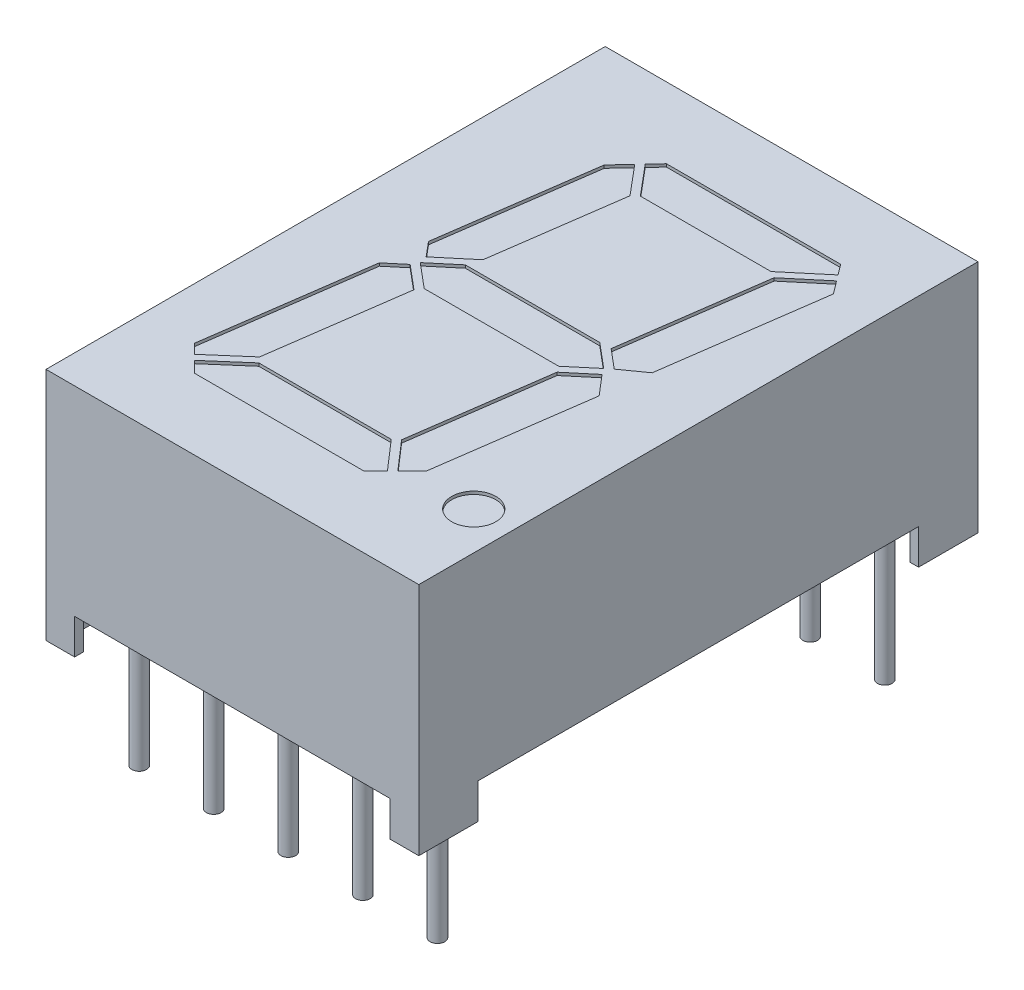
from build123d import *

# Parameters (mm, degrees)
SKETCH1_W          = 12.7
SKETCH1_H          = 19.05
EXTRUDE2_DEPTH     = 8
SKETCH2_W          = 5.375
SKETCH2_H          = 1.2
CUT_EXTRUDE2_DEPTH = 22.615388037
SKETCH3_W          = 15
SKETCH3_H          = 1.2
CUT_EXTRUDE3_DEPTH = 18.776828317
SKETCH6_R          = 0.75
CUT_EXTRUDE4_DEPTH = 0.1
SKETCH7_W          = 0.675
SKETCH7_H          = 1.725
CUT_EXTRUDE6_DEPTH = 1.2
SKETCH7_3_R        = 0.25
EXTRUDE3_DEPTH     = 1.2
SKETCH7_4_R        = 0.25
SKETCH7_4_W        = 0.675
SKETCH7_4_H        = 1.725
EXTRUDE4_DEPTH     = 4
SKETCH8_W          = 0.025316456
SKETCH8_H          = 0.026582278
CUT_EXTRUDE7_DEPTH = 0.01


with BuildPart() as part:
    # Sketch1 → Extrude2 (new body)
    with BuildSketch(Plane(origin=(0, 0, 0), x_dir=(1, 0, 0), z_dir=(0, 1, 0))):
        Rectangle(SKETCH1_W, SKETCH1_H)
    extrude(amount=-EXTRUDE2_DEPTH)

    # Sketch2 → Cut-Extrude2 (cut, through all)
    with BuildSketch(Plane.XY.offset(9.525)):
        with Locations((-2.6875, -7.4)):
            Rectangle(SKETCH2_W, SKETCH2_H)
        with Locations((2.6875, -7.4)):
            Rectangle(SKETCH2_W, SKETCH2_H)
    extrude(amount=-CUT_EXTRUDE2_DEPTH, mode=Mode.SUBTRACT)

    # Sketch3 → Cut-Extrude3 (cut, through all)
    with BuildSketch(Plane(origin=(6.35, 0, 0), x_dir=(0, 0, -1), z_dir=(1, 0, 0))):
        with Locations((0, -7.4)):
            Rectangle(SKETCH3_W, SKETCH3_H)
    extrude(amount=-CUT_EXTRUDE3_DEPTH, mode=Mode.SUBTRACT)

    # Sketch6 → Cut-Extrude4 (cut)
    with BuildSketch(Plane(origin=(0, 0, 0), x_dir=(-1, 0, 0), z_dir=(0, 1, 0))):
        Polygon((2.369327945, -6.551337949), (2.871364694, -6.012969448), (3.609010213, -0.764348857), (3.193357415, -0.268993141), (2.140736033, -1.152247354), (1.523595157, -5.543432859), align=None)
        Polygon((-4.085129092, -7.11), (1.848367154, -7.11), (2.197547933, -6.735549459), (1.337009761, -5.71), (-3.11477849, -5.71), (-4.355553886, -6.751134178), align=None)
        Polygon((3.244309033, 0.226239657), (3.815599337, 0.705609141), (4.591456053, 6.226116524), (4.264982567, 6.552590009), (3.078645126, 5.521322605), (2.430446711, 0.909151231), align=None)
        Polygon((-4.837397871, -6.111705612), (-4.506214117, -6.551201299), (-3.348930492, -5.580125036), (-2.664827887, -0.712482073), (-3.321818844, -0.161201203), (-4.076647, -0.698681899), align=None)
        Polygon((-2.290772485, -0.7), (2.290772485, -0.7), (3.125, 0), (2.290772485, 0.7), (-2.290772485, 0.7), (-3.125, 0), align=None)
        Polygon((2.914630368, 5.71), (4.087774201, 6.729798375), (3.707572576, 7.11), (-2.067614222, 7.11), (-2.466679527, 6.710934695), (-1.596580271, 5.71), align=None)
        Polygon((-3.128274394, 6.049339828), (-3.854004606, 0.88550105), (-3.271336503, 0.203560916), (-2.437787921, 0.902991224), (-1.785257666, 5.545985243), (-2.643887893, 6.533726329), align=None)
        with Locations(Location((-5.058047449, 6.36, 0), (0, 0, 90))):
            Circle(SKETCH6_R)
    extrude(amount=-CUT_EXTRUDE4_DEPTH, mode=Mode.SUBTRACT)

    # Sketch7 → Cut-Extrude6 (cut)
    with BuildSketch(Plane.XZ.offset(8)):
        with Locations((-5.7125, 8.3625)):
            Rectangle(SKETCH7_W, SKETCH7_H)
        with Locations((-5.7125, -8.3625)):
            Rectangle(SKETCH7_W, SKETCH7_H)
        with Locations((5.7125, -8.3625)):
            Rectangle(SKETCH7_W, SKETCH7_H)
        with Locations((5.7125, 8.3625)):
            Rectangle(SKETCH7_W, SKETCH7_H)
    extrude(amount=-CUT_EXTRUDE6_DEPTH, mode=Mode.SUBTRACT)

    # Sketch7_3 → Extrude3 (add)
    with BuildSketch(Plane.XZ.offset(8)):
        with Locations(Location((-5.08, 7.62, 0), (0, 0, 270))):
            Circle(SKETCH7_3_R)
        with Locations(Location((-2.54, 7.62, 0), (0, 0, 270))):
            Circle(SKETCH7_3_R)
        with Locations(Location((0, 7.62, 0), (0, 0, 270))):
            Circle(SKETCH7_3_R)
        with Locations(Location((5.08, 7.62, 0), (0, 0, 270))):
            Circle(SKETCH7_3_R)
        with Locations(Location((2.54, 7.62, 0), (0, 0, 270))):
            Circle(SKETCH7_3_R)
        with Locations(Location((2.54, -7.62, 0), (0, 0, 270))):
            Circle(SKETCH7_3_R)
        with Locations(Location((5.08, -7.62, 0), (0, 0, 270))):
            Circle(SKETCH7_3_R)
        with Locations(Location((0, -7.62, 0), (0, 0, 270))):
            Circle(SKETCH7_3_R)
        with Locations(Location((-2.54, -7.62, 0), (0, 0, 270))):
            Circle(SKETCH7_3_R)
        with Locations(Location((-5.08, -7.62, 0), (0, 0, 270))):
            Circle(SKETCH7_3_R)
    extrude(amount=-EXTRUDE3_DEPTH)


with BuildPart() as extrude4_tool:
    # Sketch7_4 → Extrude4 (new body)
    with BuildSketch(Plane.XZ.offset(8)):
        with Locations(Location((-5.08, 7.62, 0), (0, 0, 270))):
            Circle(SKETCH7_4_R)
        with Locations(Location((-2.54, 7.62, 0), (0, 0, 270))):
            Circle(SKETCH7_4_R)
        with Locations(Location((0, 7.62, 0), (0, 0, 270))):
            Circle(SKETCH7_4_R)
        with Locations(Location((5.08, 7.62, 0), (0, 0, 270))):
            Circle(SKETCH7_4_R)
        with Locations(Location((2.54, 7.62, 0), (0, 0, 270))):
            Circle(SKETCH7_4_R)
        with Locations(Location((2.54, -7.62, 0), (0, 0, 270))):
            Circle(SKETCH7_4_R)
        with Locations(Location((5.08, -7.62, 0), (0, 0, 270))):
            Circle(SKETCH7_4_R)
        with Locations(Location((0, -7.62, 0), (0, 0, 270))):
            Circle(SKETCH7_4_R)
        with Locations(Location((-2.54, -7.62, 0), (0, 0, 270))):
            Circle(SKETCH7_4_R)
        with Locations(Location((-5.08, -7.62, 0), (0, 0, 270))):
            Circle(SKETCH7_4_R)
        with Locations((-5.7125, 8.3625)):
            Rectangle(SKETCH7_4_W, SKETCH7_4_H)
        with Locations((-5.7125, -8.3625)):
            Rectangle(SKETCH7_4_W, SKETCH7_4_H)
        with Locations((5.7125, -8.3625)):
            Rectangle(SKETCH7_4_W, SKETCH7_4_H)
        with Locations((5.7125, 8.3625)):
            Rectangle(SKETCH7_4_W, SKETCH7_4_H)
    extrude(amount=EXTRUDE4_DEPTH)


with BuildPart() as part_1:
    add(part.part)


with BuildPart() as part_2:
    # Extrude4: joined with extrude4_tool
    add(part_1.part.fuse(extrude4_tool.part, tol=0.00001))


with BuildPart() as extrude4_kept_piece:
    # of the separate pieces the step leaves, the one the design keeps (extrude4_pieces_kept)
    add(part_2.part.solids().sort_by_distance((-6.35, 0, -9.525))[0])

    # Sketch8 → Cut-Extrude7 (cut)
    with BuildSketch(Plane.XZ.offset(6.8)):
        Polygon((0.572151899, 6.217942251), (0.595609177, 6.292625795), (0.620352057, 6.292625795), (0.636768196, 6.242289561), (0.652294304, 6.292625795), (0.678026108, 6.292625795), (0.701265823, 6.217942251), (0.676087816, 6.217942251), (0.663093354, 6.269425637), (0.646677215, 6.217942251), (0.625178006, 6.217942251), (0.608860759, 6.269425637), (0.596044304, 6.217942251), align=None)
        Polygon((0.437974684, 6.217942251), (0.461431962, 6.292625795), (0.486174842, 6.292625795), (0.502590981, 6.242289561), (0.518117089, 6.292625795), (0.543848892, 6.292625795), (0.567088608, 6.217942251), (0.541910601, 6.217942251), (0.528916139, 6.269425637), (0.5125, 6.217942251), (0.491000791, 6.217942251), (0.474683544, 6.269425637), (0.461867089, 6.217942251), align=None)
        Polygon((0.303797468, 6.217942251), (0.327254747, 6.292625795), (0.351997627, 6.292625795), (0.368413766, 6.242289561), (0.383939873, 6.292625795), (0.409671677, 6.292625795), (0.432911392, 6.217942251), (0.407733386, 6.217942251), (0.394738924, 6.269425637), (0.378322785, 6.217942251), (0.356823576, 6.217942251), (0.340506329, 6.269425637), (0.327689873, 6.217942251), align=None)
        with Locations((0.275949367, 6.279334656)):
            Rectangle(SKETCH8_W, SKETCH8_H)
        with BuildLine():
            add(Edge.make_bspline(
                [(0.159493671, 6.261454909), (0.159530199, 6.262677023), (0.159601928, 6.265076848), (0.16021109, 6.268584813), (0.161206614, 6.271908097), (0.162570953, 6.275070812), (0.164384941, 6.278026178), (0.166539954, 6.280844745), (0.169151869, 6.283428707), (0.172088905, 6.285867468), (0.175386832, 6.288049863), (0.178989454, 6.289950002), (0.182859774, 6.29157472), (0.187013794, 6.29290641), (0.191459372, 6.293897177), (0.196177149, 6.294620494), (0.201170497, 6.295094002), (0.204594085, 6.295135943), (0.206348892, 6.295157441)],
                knots=[0, 0, 0, 0, 0.907421153, 1.781872267, 2.635683434, 3.480115191, 4.332689235, 5.205575272, 6.109500117, 7.055808355, 8.037942167, 9.041423561, 10.07750834, 11.152467461, 12.277657752, 13.45734338, 14.696726425, 16, 16, 16, 16], degree=3))
            add(Edge.make_bspline(
                [(0.206348892, 6.295157441), (0.208366877, 6.295130176), (0.212275063, 6.295077372), (0.217942631, 6.294691999), (0.223206098, 6.29400405), (0.228103845, 6.293047469), (0.232708145, 6.291844184), (0.23714149, 6.29055354), (0.241422782, 6.28908896), (0.244195874, 6.287988823), (0.24556962, 6.287443833)],
                knots=[0, 0, 0, 0, 1.203182053, 2.33017619, 3.384818652, 4.366208123, 5.30340534, 6.221361684, 7.118890722, 8, 8, 8, 8], degree=3))
            Line((0.24556962, 6.287443833), (0.24556962, 6.263511871))
            Line((0.24556962, 6.263511871), (0.242721519, 6.263511871))
            add(Edge.make_bspline(
                [(0.242721519, 6.263511871), (0.241355956, 6.264592834), (0.238632846, 6.266748413), (0.234205888, 6.269516767), (0.229546876, 6.271889778), (0.224708482, 6.2738724), (0.219807114, 6.275448014), (0.214938046, 6.27657492), (0.210169064, 6.277314284), (0.207010742, 6.277395846), (0.205458861, 6.277435922)],
                knots=[0, 0, 0, 0, 1.030738938, 2.055426519, 3.085610749, 4.123842265, 5.148648843, 6.130724483, 7.081507926, 8, 8, 8, 8], degree=3))
            add(Edge.make_bspline(
                [(0.205458861, 6.277435922), (0.205030115, 6.277434621), (0.204112202, 6.277431837), (0.202643054, 6.277310522), (0.200986711, 6.277182677), (0.199205972, 6.276986563), (0.197418768, 6.276755418), (0.19575852, 6.276408951), (0.194257758, 6.2760398), (0.193351089, 6.275672534), (0.192919304, 6.275497631)],
                knots=[0, 0, 0, 0, 0.806537132, 1.726733348, 2.77251655, 3.932999672, 5.098049949, 6.161349231, 7.124375527, 8, 8, 8, 8], degree=3))
            add(Edge.make_bspline(
                [(0.192919304, 6.275497631), (0.192439817, 6.275269395), (0.191497525, 6.274820864), (0.190194994, 6.274006953), (0.189024509, 6.273112209), (0.187963807, 6.272150475), (0.187101412, 6.270987487), (0.186480251, 6.269588216), (0.18613568, 6.267938924), (0.186096608, 6.266763762), (0.186075949, 6.266142409)],
                knots=[0, 0, 0, 0, 1.02474257, 2.013837243, 2.958431669, 3.867978675, 4.769292696, 5.732237074, 6.800947934, 8, 8, 8, 8], degree=3))
            add(Edge.make_bspline(
                [(0.186075949, 6.266142409), (0.186107411, 6.265596543), (0.186169273, 6.264523209), (0.186750779, 6.26299478), (0.187634826, 6.261574644), (0.188914241, 6.260309307), (0.190527919, 6.259183195), (0.192458907, 6.258172432), (0.194732757, 6.257336674), (0.19636997, 6.256898802), (0.197231013, 6.256668517)],
                knots=[0, 0, 0, 0, 0.825427492, 1.623033598, 2.45033906, 3.348940377, 4.33183287, 5.428402891, 6.647546779, 8, 8, 8, 8], degree=3))
            add(Edge.make_bspline(
                [(0.197231013, 6.256668517), (0.199200253, 6.256223312), (0.203235465, 6.255311034), (0.209375278, 6.25412358), (0.215513981, 6.252897709), (0.219470238, 6.251683394), (0.221400316, 6.251090985)],
                knots=[0, 0, 0, 0, 0.976118991, 2.000185432, 3.024380873, 4, 4, 4, 4], degree=3))
            add(Edge.make_bspline(
                [(0.221400316, 6.251090985), (0.222438469, 6.250737262), (0.224459331, 6.250048708), (0.227358523, 6.248896059), (0.230001771, 6.247590925), (0.23245931, 6.246268887), (0.234651974, 6.24478883), (0.236646608, 6.24325607), (0.238399268, 6.241603266), (0.239925706, 6.239853773), (0.241268572, 6.238017411), (0.242421982, 6.23607027), (0.243383004, 6.234003821), (0.244206396, 6.231848423), (0.244817623, 6.229573888), (0.245240059, 6.227197471), (0.245538122, 6.224713985), (0.245558978, 6.223019649), (0.24556962, 6.222155067)],
                knots=[0, 0, 0, 0, 1.287376879, 2.505999703, 3.65855109, 4.746193839, 5.778582289, 6.760029101, 7.696159662, 8.601061861, 9.48181646, 10.363080883, 11.252765705, 12.153987336, 13.068239035, 14.012364187, 14.985753787, 16, 16, 16, 16], degree=3))
            add(Edge.make_bspline(
                [(0.24556962, 6.222155067), (0.24553232, 6.220998921), (0.245458913, 6.218723646), (0.244857463, 6.215394624), (0.243830953, 6.212245805), (0.242444593, 6.209242649), (0.2406171, 6.206428386), (0.238424977, 6.203750899), (0.235814667, 6.201258403), (0.23282934, 6.198959767), (0.229542493, 6.196880961), (0.226008488, 6.195044253), (0.222229636, 6.193537806), (0.218249751, 6.192256575), (0.214030359, 6.19130418), (0.209593388, 6.190584602), (0.204919526, 6.190171601), (0.201728115, 6.190120326), (0.200098892, 6.19009415)],
                knots=[0, 0, 0, 0, 0.894901293, 1.761149761, 2.608783409, 3.453876344, 4.314933854, 5.200038827, 6.12799933, 7.103249695, 8.113098521, 9.136064399, 10.182719798, 11.259667356, 12.370545059, 13.528828137, 14.738461593, 16, 16, 16, 16], degree=3))
            add(Edge.make_bspline(
                [(0.200098892, 6.19009415), (0.198430241, 6.190116542), (0.195095767, 6.19016129), (0.190113794, 6.19053626), (0.185156379, 6.191102761), (0.180284815, 6.191902215), (0.175602308, 6.192919871), (0.171185694, 6.194005829), (0.167106724, 6.195246219), (0.164532999, 6.196200264), (0.163291139, 6.196660605)],
                knots=[0, 0, 0, 0, 1.065379838, 2.128953261, 3.188461447, 4.250817766, 5.279613205, 6.247547721, 7.154416075, 8, 8, 8, 8], degree=3))
            Line((0.163291139, 6.196660605), (0.163291139, 6.219208074))
            Line((0.163291139, 6.219208074), (0.166119462, 6.219208074))
            add(Edge.make_bspline(
                [(0.166119462, 6.219208074), (0.167192422, 6.21840787), (0.169386652, 6.216771432), (0.173045405, 6.214685455), (0.177009465, 6.212735941), (0.181274367, 6.211014148), (0.185746907, 6.209593547), (0.190324453, 6.208564503), (0.194951518, 6.20792538), (0.198053109, 6.207852247), (0.19960443, 6.207815669)],
                knots=[0, 0, 0, 0, 0.89224925, 1.824673196, 2.804309561, 3.838364047, 4.890042674, 5.931526337, 6.965412421, 8, 8, 8, 8], degree=3))
            add(Edge.make_bspline(
                [(0.19960443, 6.207815669), (0.20069973, 6.207839878), (0.202889476, 6.207888279), (0.206163883, 6.208237533), (0.209398675, 6.208909274), (0.211441573, 6.209723611), (0.212460443, 6.210129751)],
                knots=[0, 0, 0, 0, 0.998993879, 1.997209027, 3.00113285, 4, 4, 4, 4], degree=3))
            add(Edge.make_bspline(
                [(0.212460443, 6.210129751), (0.212893922, 6.210331234), (0.213760592, 6.210734065), (0.214967595, 6.211506391), (0.216070899, 6.212436108), (0.217071904, 6.213488502), (0.21791996, 6.214657837), (0.21855762, 6.215927596), (0.218918439, 6.217289575), (0.218964276, 6.218223744), (0.218987342, 6.218693833)],
                knots=[0, 0, 0, 0, 1.005454979, 2.010239304, 3.005296729, 4.036100111, 5.060531193, 6.034954812, 7.011155677, 8, 8, 8, 8], degree=3))
            add(Edge.make_bspline(
                [(0.218987342, 6.218693833), (0.218952547, 6.219331764), (0.218886059, 6.220550792), (0.218286061, 6.222264488), (0.217288392, 6.2237276), (0.216135293, 6.224720594), (0.215018314, 6.225419353), (0.213977797, 6.225924593), (0.212778346, 6.226438016), (0.211400897, 6.226927213), (0.209865762, 6.227421259), (0.20815684, 6.227895929), (0.206274232, 6.228345489), (0.204958342, 6.228631641), (0.204272152, 6.228780858)],
                knots=[0, 0, 0, 0, 1.174343879, 2.244064321, 3.303704314, 4.407076671, 5.02483983, 5.732197225, 6.53898402, 7.431906431, 8.428480183, 9.514816237, 10.704066255, 12, 12, 12, 12], degree=3))
            add(Edge.make_bspline(
                [(0.204272152, 6.228780858), (0.202439527, 6.229157579), (0.198838824, 6.22989775), (0.193433749, 6.230992047), (0.187940695, 6.232304565), (0.184270145, 6.233433777), (0.182357595, 6.234022156)],
                knots=[0, 0, 0, 0, 0.995788186, 1.956503735, 2.935230479, 4, 4, 4, 4], degree=3))
            add(Edge.make_bspline(
                [(0.182357595, 6.234022156), (0.181411038, 6.234341397), (0.179559421, 6.234965885), (0.176918823, 6.236052203), (0.17447165, 6.237226061), (0.172205016, 6.23846803), (0.17012965, 6.239810463), (0.16824336, 6.241235796), (0.166545403, 6.242740579), (0.165056655, 6.244356299), (0.163727897, 6.246066647), (0.162615553, 6.24791726), (0.161619968, 6.249860789), (0.160866813, 6.251954233), (0.160242304, 6.25415276), (0.159820561, 6.256484694), (0.159526198, 6.258928912), (0.159504634, 6.260603512), (0.159493671, 6.261454909)],
                knots=[0, 0, 0, 0, 1.237326419, 2.420410185, 3.534642089, 4.598489486, 5.620241961, 6.59385002, 7.525152549, 8.426792174, 9.312230456, 10.203151844, 11.098070343, 12.012931196, 12.954244379, 13.926618287, 14.945853925, 16, 16, 16, 16], degree=3))
        make_face()
        with BuildLine():
            Line((0.067088608, 6.292625795), (0.091139241, 6.292625795))
            Line((0.091139241, 6.292625795), (0.091139241, 6.284793517))
            add(Edge.make_bspline(
                [(0.091139241, 6.284793517), (0.092232434, 6.285602312), (0.094340096, 6.287161656), (0.097514655, 6.289238718), (0.100532955, 6.29102314), (0.103463307, 6.292546258), (0.106469584, 6.293758428), (0.109707718, 6.294576809), (0.113209314, 6.295079533), (0.115636384, 6.295130894), (0.116890823, 6.295157441)],
                knots=[0, 0, 0, 0, 1.150945962, 2.219006967, 3.209666795, 4.118194914, 5.012574058, 5.946577101, 6.93868214, 8, 8, 8, 8], degree=3))
            add(Edge.make_bspline(
                [(0.116890823, 6.295157441), (0.117907098, 6.295134493), (0.119886079, 6.295089807), (0.122764378, 6.294748086), (0.125466344, 6.294199677), (0.127995181, 6.293431271), (0.130344881, 6.29242824), (0.132488561, 6.291156605), (0.134491138, 6.289723891), (0.136273085, 6.288017526), (0.137888631, 6.286119607), (0.139271202, 6.283987198), (0.140448907, 6.281654258), (0.141390007, 6.279102409), (0.142145096, 6.276344104), (0.142669028, 6.273364857), (0.142989621, 6.270177729), (0.14302156, 6.267982599), (0.143037975, 6.266854434)],
                knots=[0, 0, 0, 0, 1.108959949, 2.159465255, 3.158589008, 4.114545495, 5.039534357, 5.93921201, 6.830099133, 7.720870013, 8.624681761, 9.544731627, 10.487599671, 11.471264588, 12.508152322, 13.604835107, 14.769030043, 16, 16, 16, 16], degree=3))
            Line((0.143037975, 6.266854434), (0.143037975, 6.217942251))
            Line((0.143037975, 6.217942251), (0.118987342, 6.217942251))
            Line((0.118987342, 6.217942251), (0.118987342, 6.255521365))
            add(Edge.make_bspline(
                [(0.118987342, 6.255521365), (0.118985706, 6.256437836), (0.118982576, 6.258192051), (0.118900237, 6.260697858), (0.118779336, 6.262966031), (0.118640631, 6.265008059), (0.118387615, 6.26685481), (0.118009906, 6.268520971), (0.11753908, 6.270040573), (0.117074761, 6.270947274), (0.116851266, 6.271383707)],
                knots=[0, 0, 0, 0, 1.361401701, 2.605856924, 3.723918663, 4.735739235, 5.645738665, 6.489217889, 7.27279937, 8, 8, 8, 8], degree=3))
            add(Edge.make_bspline(
                [(0.116851266, 6.271383707), (0.116621257, 6.271782412), (0.11616908, 6.272566233), (0.115248816, 6.273572545), (0.114169974, 6.274416295), (0.11289277, 6.275074396), (0.111403203, 6.275564899), (0.109682344, 6.27594547), (0.107690603, 6.276117348), (0.106283135, 6.276151839), (0.105537975, 6.276170099)],
                knots=[0, 0, 0, 0, 0.849004071, 1.669068917, 2.503060811, 3.370079215, 4.310762265, 5.396376419, 6.621555549, 8, 8, 8, 8], degree=3))
            add(Edge.make_bspline(
                [(0.105537975, 6.276170099), (0.104997032, 6.27615026), (0.103885616, 6.276109498), (0.102168163, 6.275917958), (0.100378903, 6.275518799), (0.097860234, 6.274873854), (0.094695025, 6.27368), (0.09233549, 6.272326853), (0.091139241, 6.271640827)],
                knots=[0, 0, 0, 0, 0.638062719, 1.310959128, 2.033463623, 2.796942592, 4.376095945, 6, 6, 6, 6], degree=3))
            Line((0.091139241, 6.271640827), (0.091139241, 6.217942251))
            Line((0.091139241, 6.217942251), (0.067088608, 6.217942251))
            Line((0.067088608, 6.217942251), (0.067088608, 6.292625795))
        make_face()
        with BuildLine():
            Line((-0.030379747, 6.292625795), (-0.006329114, 6.292625795))
            Line((-0.006329114, 6.292625795), (-0.006329114, 6.255046681))
            add(Edge.make_bspline(
                [(-0.006329114, 6.255046681), (-0.006304108, 6.253516692), (-0.006254136, 6.2504592), (-0.005977585, 6.246696106), (-0.005593098, 6.243854567), (-0.005225559, 6.242022978), (-0.004793687, 6.240474861), (-0.004381426, 6.2395891), (-0.004193038, 6.23918434)],
                knots=[0, 0, 0, 0, 1.709111167, 3.415443484, 4.21113913, 4.910175115, 5.501990373, 6, 6, 6, 6], degree=3))
            add(Edge.make_bspline(
                [(-0.004193038, 6.23918434), (-0.003948577, 6.238786277), (-0.003469277, 6.238005818), (-0.002531926, 6.236992942), (-0.001438143, 6.236163573), (-0.000166967, 6.235484106), (0.001321142, 6.235004918), (0.003045059, 6.234652164), (0.005025244, 6.23444161), (0.006434073, 6.234413057), (0.007179589, 6.234397947)],
                knots=[0, 0, 0, 0, 0.860202684, 1.686548532, 2.528236983, 3.382486038, 4.33249885, 5.401154041, 6.624757403, 8, 8, 8, 8], degree=3))
            add(Edge.make_bspline(
                [(0.007179589, 6.234397947), (0.008310478, 6.234458048), (0.010618173, 6.234580689), (0.013493483, 6.235247355), (0.015810821, 6.23610732), (0.017668538, 6.236857755), (0.01957626, 6.237831856), (0.020855802, 6.238553297), (0.021518987, 6.238927219)],
                knots=[0, 0, 0, 0, 1.33818541, 2.730705359, 3.468371228, 4.262126284, 5.099261778, 6, 6, 6, 6], degree=3))
            Line((0.021518987, 6.238927219), (0.021518987, 6.292625795))
            Line((0.021518987, 6.292625795), (0.04556962, 6.292625795))
            Line((0.04556962, 6.292625795), (0.04556962, 6.217942251))
            Line((0.04556962, 6.217942251), (0.021518987, 6.217942251))
            Line((0.021518987, 6.217942251), (0.021518987, 6.225774529))
            add(Edge.make_bspline(
                [(0.021518987, 6.225774529), (0.020461581, 6.224968378), (0.018403276, 6.223399156), (0.015224038, 6.221358735), (0.01214014, 6.219559966), (0.009087131, 6.218047149), (0.005972176, 6.216840374), (0.002709417, 6.216029385), (-0.000706989, 6.215485583), (-0.003043704, 6.215435889), (-0.004232595, 6.215410605)],
                knots=[0, 0, 0, 0, 1.126119141, 2.192057864, 3.198061997, 4.149848529, 5.076251285, 6.021887753, 6.99356175, 8, 8, 8, 8], degree=3))
            add(Edge.make_bspline(
                [(-0.004232595, 6.215410605), (-0.00522886, 6.215436006), (-0.007173746, 6.215485592), (-0.010008596, 6.215795144), (-0.012679702, 6.216346367), (-0.015173087, 6.217142223), (-0.017508773, 6.218133582), (-0.019682445, 6.219337562), (-0.021668294, 6.220800843), (-0.023496446, 6.222460782), (-0.025135546, 6.224352079), (-0.026532456, 6.226481457), (-0.027736818, 6.228818377), (-0.028686083, 6.231381015), (-0.029477407, 6.234147286), (-0.02998217, 6.237145916), (-0.030339823, 6.240355802), (-0.030366173, 6.242571952), (-0.030379747, 6.243713612)],
                knots=[0, 0, 0, 0, 1.08828964, 2.12453497, 3.110382522, 4.062402335, 4.978696626, 5.878225494, 6.769849763, 7.667011675, 8.57076823, 9.495541561, 10.442454184, 11.436213583, 12.475881554, 13.580560132, 14.753614518, 16, 16, 16, 16], degree=3))
            Line((-0.030379747, 6.243713612), (-0.030379747, 6.292625795))
        make_face()
        Polygon((-0.125316456, 6.292625795), (-0.053164557, 6.292625795), (-0.053164557, 6.192625795), (-0.078481013, 6.192625795), (-0.078481013, 6.273638453), (-0.125316456, 6.273638453), align=None)
        Polygon((-0.212658228, 6.292625795), (-0.140506329, 6.292625795), (-0.140506329, 6.192625795), (-0.212658228, 6.192625795), (-0.212658228, 6.211613137), (-0.165822785, 6.211613137), (-0.165822785, 6.229334656), (-0.208860759, 6.229334656), (-0.208860759, 6.248321998), (-0.165822785, 6.248321998), (-0.165822785, 6.273638453), (-0.212658228, 6.273638453), align=None)
        with BuildLine():
            add(Edge.make_bspline(
                [(-0.329113924, 6.242724688), (-0.329094609, 6.243872376), (-0.329056357, 6.246145263), (-0.328761165, 6.249510069), (-0.32823514, 6.252775745), (-0.327555959, 6.255959993), (-0.326633453, 6.259038921), (-0.325551739, 6.262046498), (-0.324242093, 6.264951992), (-0.322737241, 6.267753426), (-0.321087768, 6.270425529), (-0.319313019, 6.272945738), (-0.31746724, 6.275328955), (-0.315477927, 6.277523849), (-0.313398746, 6.279565869), (-0.311223217, 6.281456683), (-0.308918153, 6.283160114), (-0.30731099, 6.284182998), (-0.30650712, 6.284694624)],
                knots=[0, 0, 0, 0, 1.105570398, 2.18947457, 3.250358341, 4.290584537, 5.323553275, 6.344225964, 7.367641686, 8.3905646, 9.405808457, 10.390761353, 11.358902336, 12.307789878, 13.241960776, 14.165076779, 15.082208636, 16, 16, 16, 16], degree=3))
            add(Edge.make_bspline(
                [(-0.30650712, 6.284694624), (-0.305267933, 6.285406945), (-0.302783236, 6.286835222), (-0.298798778, 6.288501062), (-0.294677169, 6.289915284), (-0.290317988, 6.290928725), (-0.285679267, 6.29169856), (-0.280674456, 6.292246731), (-0.27526755, 6.292552234), (-0.271532557, 6.292600716), (-0.269600475, 6.292625795)],
                knots=[0, 0, 0, 0, 0.896321744, 1.797216976, 2.705381885, 3.628777036, 4.602292017, 5.655629376, 6.787275635, 8, 8, 8, 8], degree=3))
            Line((-0.269600475, 6.292625795), (-0.234177215, 6.292625795))
            Line((-0.234177215, 6.292625795), (-0.234177215, 6.192625795))
            Line((-0.234177215, 6.192625795), (-0.270609177, 6.192625795))
            add(Edge.make_bspline(
                [(-0.270609177, 6.192625795), (-0.272587873, 6.192642605), (-0.276404533, 6.19267503), (-0.281921849, 6.193089957), (-0.287024188, 6.19369572), (-0.291713768, 6.194589906), (-0.296016217, 6.195704487), (-0.299933509, 6.197093018), (-0.303549742, 6.198585635), (-0.305728277, 6.199860189), (-0.306784019, 6.200477852)],
                knots=[0, 0, 0, 0, 1.267083275, 2.444046388, 3.541868212, 4.55639609, 5.499737919, 6.385160515, 7.217431253, 8, 8, 8, 8], degree=3))
            add(Edge.make_bspline(
                [(-0.306784019, 6.200477852), (-0.307634972, 6.201014393), (-0.309327097, 6.202081306), (-0.311728312, 6.203863159), (-0.313957739, 6.205819236), (-0.316086242, 6.207871054), (-0.318066059, 6.210073941), (-0.319909259, 6.212412648), (-0.321613076, 6.214890742), (-0.323171039, 6.217500211), (-0.324591854, 6.220230263), (-0.32578116, 6.223103322), (-0.326830509, 6.226081852), (-0.327636046, 6.229190815), (-0.32833396, 6.232398651), (-0.328768694, 6.235739995), (-0.329055305, 6.239192483), (-0.32909422, 6.241537373), (-0.329113924, 6.242724688)],
                knots=[0, 0, 0, 0, 0.964065863, 1.917049184, 2.86229036, 3.805247319, 4.749389377, 5.698846072, 6.657678277, 7.629829384, 8.610569287, 9.604676042, 10.607940105, 11.6349849, 12.681042988, 13.752616828, 14.862056989, 16, 16, 16, 16], degree=3))
        make_face()
        with BuildLine():
            add(Edge.make_bspline(
                [(-0.302531646, 6.24256646), (-0.302488343, 6.24098803), (-0.30240473, 6.23794023), (-0.301699336, 6.233544586), (-0.300560086, 6.229501636), (-0.299222393, 6.22638922), (-0.297885002, 6.224115902), (-0.296757478, 6.222517632), (-0.295507812, 6.221003432), (-0.294117203, 6.219594592), (-0.292582019, 6.218287556), (-0.29092076, 6.217058646), (-0.289120719, 6.21593), (-0.287847688, 6.215269994), (-0.287203323, 6.214935922)],
                knots=[0, 0, 0, 0, 1.694683197, 3.272273219, 4.767406206, 6.197615014, 6.895990032, 7.597410435, 8.296503208, 9.002591366, 9.720792421, 10.460154445, 11.220583224, 12, 12, 12, 12], degree=3))
            add(Edge.make_bspline(
                [(-0.287203323, 6.214935922), (-0.286528388, 6.214629407), (-0.285190619, 6.214021875), (-0.283120344, 6.213287788), (-0.281027643, 6.212725461), (-0.278833415, 6.212253038), (-0.276356655, 6.211975902), (-0.273434164, 6.211763226), (-0.269977491, 6.211626298), (-0.267490895, 6.211617728), (-0.266159019, 6.211613137)],
                knots=[0, 0, 0, 0, 0.826913061, 1.638999358, 2.447478739, 3.243919028, 4.140906711, 5.225381046, 6.513851968, 8, 8, 8, 8], degree=3))
            Line((-0.266159019, 6.211613137), (-0.259493671, 6.211613137))
            Line((-0.259493671, 6.211613137), (-0.259493671, 6.273638453))
            Line((-0.259493671, 6.273638453), (-0.266159019, 6.273638453))
            add(Edge.make_bspline(
                [(-0.266159019, 6.273638453), (-0.26691721, 6.273633408), (-0.268380945, 6.273623667), (-0.270497399, 6.273584564), (-0.272462161, 6.273524247), (-0.274269511, 6.273452405), (-0.275925648, 6.273337502), (-0.277413482, 6.273168905), (-0.278755832, 6.273024518), (-0.280323467, 6.272757398), (-0.282176615, 6.272340943), (-0.284337881, 6.271662851), (-0.286478414, 6.270812432), (-0.287866987, 6.270127468), (-0.288568038, 6.26978165)],
                knots=[0, 0, 0, 0, 1.186775798, 2.291144404, 3.313233901, 4.263515562, 5.122260739, 5.910868134, 6.60717912, 7.234883681, 8.398964994, 9.577230746, 10.776813768, 12, 12, 12, 12], degree=3))
            add(Edge.make_bspline(
                [(-0.288568038, 6.26978165), (-0.289151752, 6.269438173), (-0.290299689, 6.268762689), (-0.291943833, 6.267656827), (-0.293430573, 6.266421827), (-0.294836635, 6.265138729), (-0.296089501, 6.263748275), (-0.297262794, 6.262297795), (-0.29827305, 6.260735402), (-0.299518045, 6.258541873), (-0.300737777, 6.255508503), (-0.301778537, 6.25154196), (-0.302415052, 6.24718195), (-0.302491785, 6.244144368), (-0.302531646, 6.24256646)],
                knots=[0, 0, 0, 0, 0.755109416, 1.485004392, 2.205961541, 2.908125208, 3.605307969, 4.290649036, 4.985852759, 5.676964147, 7.100721462, 8.614478074, 10.241350405, 12, 12, 12, 12], degree=3))
        make_face(mode=Mode.SUBTRACT)
        with Locations((-0.360759494, 6.279334656)):
            Rectangle(SKETCH8_W, SKETCH8_H)
        with BuildLine():
            add(Edge.make_bspline(
                [(-0.435403481, 6.295157441), (-0.433813375, 6.295135614), (-0.430692253, 6.295092773), (-0.426120809, 6.294616071), (-0.421756006, 6.293897604), (-0.417608387, 6.292879432), (-0.413701826, 6.29152309), (-0.410020773, 6.289905076), (-0.406631411, 6.28788727), (-0.404567681, 6.286310328), (-0.403540348, 6.285525321)],
                knots=[0, 0, 0, 0, 1.123606455, 2.205459211, 3.245124445, 4.248821949, 5.220056174, 6.165006393, 7.086533249, 8, 8, 8, 8], degree=3))
            add(Edge.make_bspline(
                [(-0.403540348, 6.285525321), (-0.402588601, 6.284670546), (-0.400688786, 6.282964303), (-0.398222853, 6.279992877), (-0.396099767, 6.276709833), (-0.394314215, 6.27310761), (-0.392883291, 6.269190881), (-0.391860157, 6.264946219), (-0.391240912, 6.260385439), (-0.391173746, 6.257237505), (-0.391139241, 6.255620257)],
                knots=[0, 0, 0, 0, 0.916457077, 1.82937027, 2.759194969, 3.714948755, 4.706655623, 5.743329475, 6.840637961, 8, 8, 8, 8], degree=3))
            add(Edge.make_bspline(
                [(-0.391139241, 6.255620257), (-0.391178001, 6.25391703), (-0.391253124, 6.25061595), (-0.391916883, 6.245843763), (-0.392986496, 6.241426082), (-0.394524054, 6.237374174), (-0.396454496, 6.233680982), (-0.398718989, 6.230309147), (-0.401339514, 6.227266223), (-0.403346653, 6.225520784), (-0.404351266, 6.224647156)],
                knots=[0, 0, 0, 0, 1.171797512, 2.271099083, 3.308930235, 4.294129479, 5.24602549, 6.17106565, 7.084581485, 8, 8, 8, 8], degree=3))
            add(Edge.make_bspline(
                [(-0.404351266, 6.224647156), (-0.405377179, 6.223878695), (-0.407441398, 6.22233249), (-0.410844242, 6.220429879), (-0.414471932, 6.218841685), (-0.418293668, 6.217564966), (-0.422268653, 6.216610349), (-0.426332207, 6.215917683), (-0.430476009, 6.215489001), (-0.433266389, 6.215436863), (-0.434671677, 6.215410605)],
                knots=[0, 0, 0, 0, 0.952046378, 1.915591786, 2.889970712, 3.892742799, 4.906722985, 5.925995921, 6.955492795, 8, 8, 8, 8], degree=3))
            add(Edge.make_bspline(
                [(-0.434671677, 6.215410605), (-0.435918482, 6.215427003), (-0.438370122, 6.215459246), (-0.441968962, 6.215789849), (-0.44542692, 6.216291787), (-0.448733839, 6.217030359), (-0.451900836, 6.217951976), (-0.454954975, 6.218984038), (-0.457914207, 6.220119269), (-0.459814852, 6.221003546), (-0.460759494, 6.221443042)],
                knots=[0, 0, 0, 0, 1.107549047, 2.177816721, 3.208424937, 4.210433793, 5.185680559, 6.13785309, 7.074491882, 8, 8, 8, 8], degree=3))
            Line((-0.460759494, 6.221443042), (-0.460759494, 6.241992884))
            Line((-0.460759494, 6.241992884), (-0.45741693, 6.241992884))
            add(Edge.make_bspline(
                [(-0.45741693, 6.241992884), (-0.456916353, 6.241576997), (-0.455831328, 6.240675545), (-0.454064496, 6.239228958), (-0.451894176, 6.237728668), (-0.450247147, 6.236834042), (-0.449367089, 6.236356017)],
                knots=[0, 0, 0, 0, 0.792743043, 1.718305972, 2.780820752, 4, 4, 4, 4], degree=3))
            add(Edge.make_bspline(
                [(-0.449367089, 6.236356017), (-0.448438153, 6.235917378), (-0.446532244, 6.235017418), (-0.443989036, 6.23414003), (-0.441785857, 6.233614661), (-0.439972197, 6.233349096), (-0.4380379, 6.233162237), (-0.436702754, 6.233142346), (-0.436016614, 6.233132124)],
                knots=[0, 0, 0, 0, 1.332360773, 2.733622135, 3.480580446, 4.268165618, 5.10999921, 6, 6, 6, 6], degree=3))
            add(Edge.make_bspline(
                [(-0.436016614, 6.233132124), (-0.435250975, 6.233151455), (-0.433767202, 6.233188917), (-0.431606835, 6.233468965), (-0.429582217, 6.233937057), (-0.427694179, 6.234615001), (-0.425940348, 6.235466768), (-0.424320324, 6.236508213), (-0.422826892, 6.237731485), (-0.421507951, 6.239173117), (-0.420315137, 6.240752856), (-0.41929596, 6.242487024), (-0.418383497, 6.244333608), (-0.41768856, 6.246338061), (-0.417128822, 6.248466836), (-0.416739892, 6.250729956), (-0.416497934, 6.253129466), (-0.416470016, 6.254775774), (-0.416455696, 6.255620257)],
                knots=[0, 0, 0, 0, 1.087372478, 2.107277257, 3.088614887, 4.033572876, 4.950837204, 5.852283781, 6.763600506, 7.684681617, 8.621202104, 9.570420019, 10.537986648, 11.542161979, 12.577980734, 13.661919757, 14.800668594, 16, 16, 16, 16], degree=3))
            add(Edge.make_bspline(
                [(-0.416455696, 6.255620257), (-0.416470471, 6.256484414), (-0.416499177, 6.258163426), (-0.416732691, 6.260605037), (-0.417148582, 6.262886468), (-0.41771983, 6.265011788), (-0.418444178, 6.266977807), (-0.419349295, 6.268775203), (-0.420385652, 6.27043201), (-0.42163021, 6.271894622), (-0.422994093, 6.273210944), (-0.424508985, 6.274347078), (-0.426168224, 6.275295223), (-0.427950405, 6.276099686), (-0.429883445, 6.276678085), (-0.431939982, 6.277114776), (-0.434129537, 6.277403333), (-0.435639891, 6.277424896), (-0.436412184, 6.277435922)],
                knots=[0, 0, 0, 0, 1.230336593, 2.390482092, 3.487897344, 4.52859895, 5.520747884, 6.465347575, 7.38981449, 8.296085817, 9.192433006, 10.084246191, 10.984321635, 11.908883871, 12.862027947, 13.850751296, 14.901019963, 16, 16, 16, 16], degree=3))
            add(Edge.make_bspline(
                [(-0.436412184, 6.277435922), (-0.437137949, 6.277427172), (-0.4385528, 6.277410115), (-0.4406198, 6.277200561), (-0.442577305, 6.27689379), (-0.444410447, 6.276453836), (-0.44611318, 6.275941285), (-0.447669514, 6.27536834), (-0.44908249, 6.274765214), (-0.44994378, 6.274297458), (-0.450356013, 6.27407358)],
                knots=[0, 0, 0, 0, 1.201052708, 2.34140671, 3.435973211, 4.479046096, 5.459661032, 6.378175262, 7.223757638, 8, 8, 8, 8], degree=3))
            add(Edge.make_bspline(
                [(-0.450356013, 6.27407358), (-0.451056218, 6.273643686), (-0.452410785, 6.272812043), (-0.454249513, 6.271410478), (-0.455894382, 6.269996218), (-0.456918894, 6.26904), (-0.45741693, 6.268575162)],
                knots=[0, 0, 0, 0, 1.098601379, 2.125273733, 3.088655601, 4, 4, 4, 4], degree=3))
            Line((-0.45741693, 6.268575162), (-0.460759494, 6.268575162))
            Line((-0.460759494, 6.268575162), (-0.460759494, 6.289283232))
            add(Edge.make_bspline(
                [(-0.460759494, 6.289283232), (-0.459814104, 6.289720726), (-0.457923097, 6.29059582), (-0.455008518, 6.291749692), (-0.452020545, 6.292717852), (-0.448972172, 6.293620933), (-0.445800089, 6.294309294), (-0.442477058, 6.294802417), (-0.43899556, 6.29510333), (-0.436617171, 6.295139158), (-0.435403481, 6.295157441)],
                knots=[0, 0, 0, 0, 0.952012952, 1.904254716, 2.862729541, 3.822037426, 4.808956931, 5.82647221, 6.890850784, 8, 8, 8, 8], degree=3))
        make_face()
        with BuildLine():
            add(Edge.make_bspline(
                [(-0.553164557, 6.25532358), (-0.553139862, 6.256828486), (-0.553091723, 6.259761952), (-0.552552407, 6.264033743), (-0.551739627, 6.268069741), (-0.550567096, 6.271856949), (-0.549086703, 6.275414224), (-0.547235764, 6.278704016), (-0.545064759, 6.281757246), (-0.542573722, 6.284547131), (-0.53977252, 6.287045641), (-0.536698338, 6.289240894), (-0.533324511, 6.291054336), (-0.5297102, 6.292566426), (-0.525825548, 6.293735662), (-0.521671329, 6.294548379), (-0.517254195, 6.295083849), (-0.514215776, 6.295132501), (-0.512658228, 6.295157441)],
                knots=[0, 0, 0, 0, 1.120167703, 2.183507516, 3.201345984, 4.182878364, 5.131270247, 6.065524964, 6.98789854, 7.91635504, 8.84481154, 9.778033504, 10.722808862, 11.691211189, 12.691525459, 13.738229926, 14.840575679, 16, 16, 16, 16], degree=3))
            add(Edge.make_bspline(
                [(-0.512658228, 6.295157441), (-0.511100707, 6.295132419), (-0.508062341, 6.295083607), (-0.503644832, 6.294549275), (-0.499485737, 6.293731325), (-0.49559643, 6.292575223), (-0.491987684, 6.291048674), (-0.488617817, 6.289241626), (-0.485544052, 6.287045433), (-0.482742566, 6.284547241), (-0.480252248, 6.281757014), (-0.478078657, 6.278704832), (-0.476236243, 6.275408878), (-0.474718389, 6.271865832), (-0.473585065, 6.268064994), (-0.472761602, 6.264034553), (-0.472225394, 6.259761733), (-0.472176819, 6.256828412), (-0.472151899, 6.25532358)],
                knots=[0, 0, 0, 0, 1.15937715, 2.261678054, 3.308339936, 4.313313916, 5.277148057, 6.221884977, 7.155068972, 8.083487698, 9.011906424, 9.934242473, 10.868459181, 11.818729666, 12.798784262, 13.81658132, 14.879877871, 16, 16, 16, 16], degree=3))
            add(Edge.make_bspline(
                [(-0.472151899, 6.25532358), (-0.472177, 6.253812147), (-0.472226044, 6.250859119), (-0.472761711, 6.246560372), (-0.473578673, 6.242499276), (-0.474744205, 6.238686725), (-0.476250482, 6.235124249), (-0.478097428, 6.23181806), (-0.480293183, 6.228771287), (-0.482802618, 6.225981122), (-0.485615383, 6.223486594), (-0.488702882, 6.221308489), (-0.492066422, 6.219499696), (-0.495666774, 6.217971931), (-0.499554435, 6.216839385), (-0.503691062, 6.216021229), (-0.508088545, 6.21548332), (-0.511107271, 6.215435285), (-0.512658228, 6.215410605)],
                knots=[0, 0, 0, 0, 1.123883205, 2.195836198, 3.217400301, 4.202580581, 5.156396106, 6.089661422, 7.013912723, 7.944661364, 8.875797629, 9.805201257, 10.748976071, 11.711828658, 12.709674189, 13.755270167, 14.846705509, 16, 16, 16, 16], degree=3))
            add(Edge.make_bspline(
                [(-0.512658228, 6.215410605), (-0.514228966, 6.215435327), (-0.51728713, 6.21548346), (-0.521730542, 6.216019663), (-0.525904381, 6.216832668), (-0.529803006, 6.217999064), (-0.533428756, 6.219510478), (-0.536788831, 6.221345135), (-0.539860139, 6.223547193), (-0.542647393, 6.226054349), (-0.545127634, 6.228859751), (-0.54729655, 6.231909374), (-0.549103768, 6.235229091), (-0.550585538, 6.238783958), (-0.551757711, 6.242577728), (-0.552578696, 6.246611834), (-0.553084687, 6.25088683), (-0.553137471, 6.253818961), (-0.553164557, 6.25532358)],
                knots=[0, 0, 0, 0, 1.167358552, 2.272800965, 3.322628764, 4.326027541, 5.29287265, 6.238482395, 7.166210353, 8.096447471, 9.020151799, 9.945039072, 10.873038967, 11.824425184, 12.804379233, 13.820580988, 14.881633558, 16, 16, 16, 16], degree=3))
        make_face()
        with BuildLine():
            add(Edge.make_bspline(
                [(-0.523457278, 6.27381646), (-0.523812282, 6.273316379), (-0.524534755, 6.272298654), (-0.525410563, 6.270594), (-0.526189141, 6.268761548), (-0.526809614, 6.266733921), (-0.527293459, 6.264438807), (-0.527601913, 6.261791252), (-0.527832257, 6.258755859), (-0.527842612, 6.256603128), (-0.527848101, 6.255462029)],
                knots=[0, 0, 0, 0, 0.765001119, 1.556867793, 2.387180485, 3.249178546, 4.200309879, 5.312433676, 6.575401142, 8, 8, 8, 8], degree=3))
            add(Edge.make_bspline(
                [(-0.527848101, 6.255462029), (-0.527830368, 6.254387155), (-0.527796392, 6.252327814), (-0.527610608, 6.24936795), (-0.527259147, 6.246678452), (-0.526765631, 6.244253744), (-0.526158041, 6.242081673), (-0.525423239, 6.240149345), (-0.524589801, 6.23843539), (-0.523904047, 6.237430269), (-0.523575949, 6.236949371)],
                knots=[0, 0, 0, 0, 1.337015307, 2.56157572, 3.686511827, 4.707709802, 5.636963675, 6.488272502, 7.276717686, 8, 8, 8, 8], degree=3))
            add(Edge.make_bspline(
                [(-0.523575949, 6.236949371), (-0.523238562, 6.236510281), (-0.522576697, 6.235648901), (-0.521401907, 6.234564013), (-0.520130386, 6.233673752), (-0.518765925, 6.232977768), (-0.517305736, 6.232496049), (-0.515803375, 6.23213956), (-0.514247193, 6.231914157), (-0.513192997, 6.231882407), (-0.512658228, 6.231866302)],
                knots=[0, 0, 0, 0, 1.058488312, 2.076474566, 3.046302828, 4.022760093, 4.996603884, 5.982315336, 6.976474174, 8, 8, 8, 8], degree=3))
            add(Edge.make_bspline(
                [(-0.512658228, 6.231866302), (-0.512130296, 6.231877248), (-0.511097679, 6.231898658), (-0.509595013, 6.23207834), (-0.508184065, 6.23237293), (-0.506844191, 6.232790863), (-0.505552217, 6.233386346), (-0.504317872, 6.234242771), (-0.503101936, 6.235318101), (-0.502363688, 6.23616862), (-0.501977848, 6.236613137)],
                knots=[0, 0, 0, 0, 1.041978199, 2.038073998, 2.982578265, 3.884042198, 4.804014415, 5.778706634, 6.839057036, 8, 8, 8, 8], degree=3))
            add(Edge.make_bspline(
                [(-0.501977848, 6.236613137), (-0.501644363, 6.237087763), (-0.500942719, 6.238086364), (-0.500059744, 6.239790884), (-0.49932839, 6.241752804), (-0.49863615, 6.243936545), (-0.498117886, 6.246407694), (-0.497717147, 6.249160972), (-0.497516433, 6.252215398), (-0.497484858, 6.254347616), (-0.497468354, 6.255462029)],
                knots=[0, 0, 0, 0, 0.706185926, 1.485796665, 2.33004681, 3.254820698, 4.274138656, 5.402098861, 6.642194297, 8, 8, 8, 8], degree=3))
            add(Edge.make_bspline(
                [(-0.497468354, 6.255462029), (-0.49747751, 6.256464489), (-0.49749524, 6.258405594), (-0.497694025, 6.261212031), (-0.498023142, 6.263815786), (-0.498498303, 6.266206416), (-0.499079056, 6.2683953), (-0.499811146, 6.270353507), (-0.500650633, 6.272101226), (-0.501345841, 6.273124907), (-0.501681171, 6.273618675)],
                knots=[0, 0, 0, 0, 1.27086383, 2.460826804, 3.565079772, 4.596261907, 5.549370831, 6.432852304, 7.244093885, 8, 8, 8, 8], degree=3))
            add(Edge.make_bspline(
                [(-0.501681171, 6.273618675), (-0.502021661, 6.27403529), (-0.502692958, 6.274856673), (-0.503842891, 6.275938831), (-0.505120324, 6.276805325), (-0.506482401, 6.277509474), (-0.507941135, 6.278037147), (-0.509487576, 6.27844439), (-0.511142843, 6.278651971), (-0.512275365, 6.278684875), (-0.512856013, 6.278701745)],
                knots=[0, 0, 0, 0, 1.011466313, 1.994169768, 2.957274081, 3.905656451, 4.870834188, 5.869371193, 6.907620549, 8, 8, 8, 8], degree=3))
            add(Edge.make_bspline(
                [(-0.512856013, 6.278701745), (-0.513857421, 6.278650096), (-0.515857557, 6.278546936), (-0.518268707, 6.277810128), (-0.520070397, 6.276958072), (-0.521322388, 6.276103611), (-0.522471325, 6.275060179), (-0.523125413, 6.274235088), (-0.523457278, 6.27381646)],
                knots=[0, 0, 0, 0, 1.484683483, 2.96539121, 3.705388955, 4.438554905, 5.207767564, 6, 6, 6, 6], degree=3))
        make_face(mode=Mode.SUBTRACT)
        with BuildLine():
            Line((-0.644303797, 6.238927219), (-0.644303797, 6.292625795))
            Line((-0.644303797, 6.292625795), (-0.620253165, 6.292625795))
            Line((-0.620253165, 6.292625795), (-0.620253165, 6.254769783))
            add(Edge.make_bspline(
                [(-0.620253165, 6.254769783), (-0.620247698, 6.253879748), (-0.62023721, 6.252172117), (-0.620204186, 6.249712503), (-0.620123915, 6.247463899), (-0.620016376, 6.2454177), (-0.619829431, 6.243558234), (-0.619518092, 6.241883399), (-0.619096595, 6.240377873), (-0.618688245, 6.239476926), (-0.61849288, 6.23904589)],
                knots=[0, 0, 0, 0, 1.339742217, 2.570446543, 3.702449567, 4.726327994, 5.654556215, 6.512888379, 7.288529137, 8, 8, 8, 8], degree=3))
            add(Edge.make_bspline(
                [(-0.61849288, 6.23904589), (-0.618282873, 6.23866068), (-0.617866586, 6.237897098), (-0.616999731, 6.236926948), (-0.615984414, 6.236122913), (-0.614820738, 6.235447342), (-0.613425719, 6.234987296), (-0.611817719, 6.23462615), (-0.609952288, 6.234449666), (-0.608630238, 6.234415836), (-0.607931171, 6.234397947)],
                knots=[0, 0, 0, 0, 0.859137151, 1.703023591, 2.531884144, 3.395689496, 4.329139829, 5.403231912, 6.626892925, 8, 8, 8, 8], degree=3))
            add(Edge.make_bspline(
                [(-0.607931171, 6.234397947), (-0.607343732, 6.234420974), (-0.606163556, 6.234467234), (-0.604408992, 6.234716637), (-0.602683056, 6.235186869), (-0.600464754, 6.236031206), (-0.597863029, 6.237268498), (-0.595886649, 6.238388766), (-0.594936709, 6.238927219)],
                knots=[0, 0, 0, 0, 0.759272211, 1.52539342, 2.28366165, 3.065252147, 4.589423829, 6, 6, 6, 6], degree=3))
            Line((-0.594936709, 6.238927219), (-0.594936709, 6.292625795))
            Line((-0.594936709, 6.292625795), (-0.570886076, 6.292625795))
            Line((-0.570886076, 6.292625795), (-0.570886076, 6.217942251))
            Line((-0.570886076, 6.217942251), (-0.594936709, 6.217942251))
            Line((-0.594936709, 6.217942251), (-0.594936709, 6.225774529))
            add(Edge.make_bspline(
                [(-0.594936709, 6.225774529), (-0.595957448, 6.224992567), (-0.597939309, 6.223474313), (-0.600960174, 6.221433043), (-0.603904448, 6.219645103), (-0.606806617, 6.218111958), (-0.609761964, 6.216885562), (-0.612851064, 6.216042052), (-0.616094623, 6.215511753), (-0.618312793, 6.215444732), (-0.619442247, 6.215410605)],
                knots=[0, 0, 0, 0, 1.13602934, 2.205708752, 3.219814904, 4.178719654, 5.103700513, 6.040802208, 7.002410817, 8, 8, 8, 8], degree=3))
            add(Edge.make_bspline(
                [(-0.619442247, 6.215410605), (-0.620645396, 6.215442529), (-0.622996866, 6.215504921), (-0.626410111, 6.216171686), (-0.629618386, 6.217184524), (-0.632592953, 6.21864157), (-0.635296134, 6.220505544), (-0.637695253, 6.222777408), (-0.639808314, 6.225425511), (-0.640898648, 6.227436827), (-0.641455696, 6.228464403)],
                knots=[0, 0, 0, 0, 1.06596181, 2.083348439, 3.072786094, 4.043114605, 5.009947443, 5.973893017, 6.964867644, 8, 8, 8, 8], degree=3))
            add(Edge.make_bspline(
                [(-0.641455696, 6.228464403), (-0.642637783, 6.227487443), (-0.644941441, 6.225583538), (-0.648495035, 6.223040842), (-0.651974192, 6.220786542), (-0.655414444, 6.218876829), (-0.658810095, 6.217331941), (-0.662189222, 6.21622634), (-0.665538003, 6.215542894), (-0.667771262, 6.215454193), (-0.668868671, 6.215410605)],
                knots=[0, 0, 0, 0, 1.188124574, 2.315425566, 3.384037189, 4.39937427, 5.362203716, 6.270239573, 7.150007311, 8, 8, 8, 8], degree=3))
            add(Edge.make_bspline(
                [(-0.668868671, 6.215410605), (-0.669851923, 6.215433991), (-0.671765068, 6.215479493), (-0.674547604, 6.215814636), (-0.67714386, 6.216385915), (-0.679567586, 6.21717828), (-0.681803526, 6.218206996), (-0.683866656, 6.219454175), (-0.685714738, 6.220964673), (-0.687407523, 6.222663364), (-0.688896667, 6.224600032), (-0.690181304, 6.22673808), (-0.691252176, 6.229084867), (-0.692141518, 6.231619563), (-0.692829665, 6.234360969), (-0.693319001, 6.237304122), (-0.693617422, 6.240443984), (-0.693652764, 6.242605342), (-0.693670886, 6.243713612)],
                knots=[0, 0, 0, 0, 1.099136554, 2.138625863, 3.127574945, 4.066908717, 4.983764051, 5.873707737, 6.754323387, 7.645578618, 8.549333854, 9.478432518, 10.428234329, 11.428300305, 12.477672891, 13.584002437, 14.761160362, 16, 16, 16, 16], degree=3))
            Line((-0.693670886, 6.243713612), (-0.693670886, 6.292625795))
            Line((-0.693670886, 6.292625795), (-0.669620253, 6.292625795))
            Line((-0.669620253, 6.292625795), (-0.669620253, 6.254769783))
            add(Edge.make_bspline(
                [(-0.669620253, 6.254769783), (-0.66961458, 6.253873164), (-0.669603692, 6.252152365), (-0.669573443, 6.249679448), (-0.669484896, 6.247424971), (-0.669403176, 6.245378619), (-0.669237293, 6.243532583), (-0.668945325, 6.241868436), (-0.668518143, 6.240382502), (-0.668126113, 6.239477602), (-0.667939082, 6.23904589)],
                knots=[0, 0, 0, 0, 1.350818449, 2.592504867, 3.725474742, 4.749698069, 5.67770978, 6.515438232, 7.29174147, 8, 8, 8, 8], degree=3))
            add(Edge.make_bspline(
                [(-0.667939082, 6.23904589), (-0.667735627, 6.238661037), (-0.667332814, 6.237899082), (-0.66648484, 6.236921876), (-0.665466156, 6.236117818), (-0.664285442, 6.235448258), (-0.662865764, 6.234984221), (-0.661236494, 6.234630815), (-0.659346013, 6.23444726), (-0.6580106, 6.234415101), (-0.657298259, 6.234397947)],
                knots=[0, 0, 0, 0, 0.846272708, 1.675499002, 2.498229298, 3.366836971, 4.305509618, 5.396757786, 6.611368595, 8, 8, 8, 8], degree=3))
            add(Edge.make_bspline(
                [(-0.657298259, 6.234397947), (-0.65629714, 6.234444877), (-0.654283331, 6.234539278), (-0.651801829, 6.235259984), (-0.649773136, 6.236066521), (-0.648089533, 6.236879739), (-0.646230816, 6.237813675), (-0.644965984, 6.238544569), (-0.644303797, 6.238927219)],
                knots=[0, 0, 0, 0, 1.291206289, 2.597335145, 3.312416795, 4.112753053, 5.011956018, 6, 6, 6, 6], degree=3))
        make_face()
    extrude(amount=-CUT_EXTRUDE7_DEPTH, mode=Mode.SUBTRACT)


solid = extrude4_kept_piece.part
